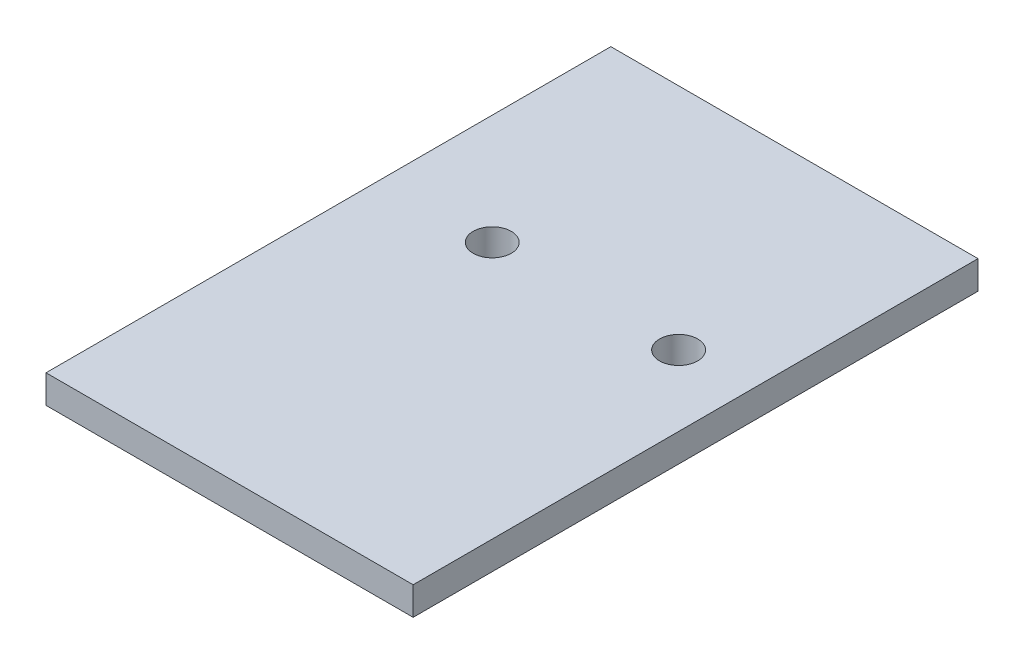
from build123d import *

# Parameters (mm, degrees)
SKETCH1_W           = 33.02
SKETCH1_H           = 50.8
SKETCH1_R           = 1.7145
BOSS_EXTRUDE1_DEPTH = 2.54


with BuildPart() as part:
    # Sketch1 → Boss-Extrude1 (new body)
    with BuildSketch(Plane(origin=(0, 0, 0), x_dir=(1, 0, 0), z_dir=(0, 1, 0))):
        with Locations((16.51, 25.4)):
            Rectangle(SKETCH1_W, SKETCH1_H)
        with Locations((9.906, 30.226)):
            Circle(SKETCH1_R, mode=Mode.SUBTRACT)
        with Locations((26.67, 30.226)):
            Circle(SKETCH1_R, mode=Mode.SUBTRACT)
    extrude(amount=BOSS_EXTRUDE1_DEPTH)


solid = part.part
